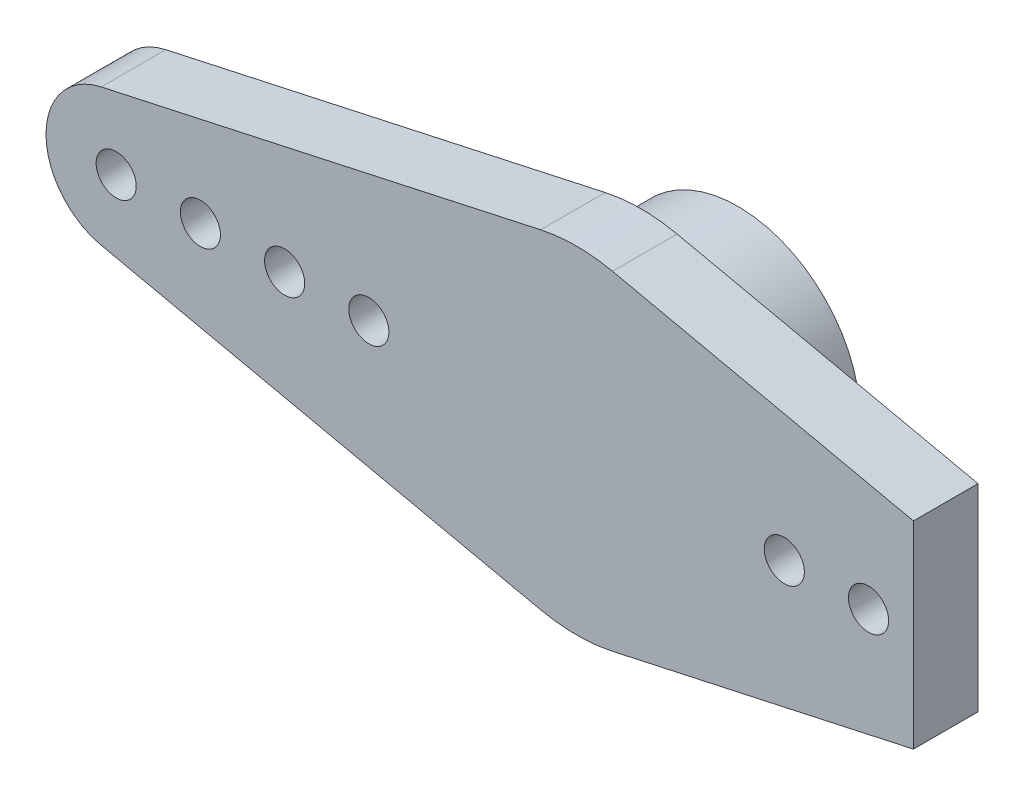
from build123d import *

# Parameters (mm, degrees)
SKETCH_1_R          = 4.35
EXTRUDE_1_DEPTH     = 3.45
SKETCH_2_R          = 0.715
EXTRUDE_2_DEPTH     = 2.3
SKETCH_3_R          = 2.85
CUT_EXTRUDE_1_DEPTH = 3.4
SKETCH_4_W          = 12.90394782
SKETCH_4_H          = 10.561384984
CUT_EXTRUDE_2_DEPTH = 10


with BuildPart() as part:
    # 草图1 → 凸台-拉伸1 (new body)
    with BuildSketch(Plane.XY):
        Circle(SKETCH_1_R)
    extrude(amount=EXTRUDE_1_DEPTH)

    # 草图2 → 凸台-拉伸2 (add)
    with BuildSketch(Plane.XY.offset(3.45)):
        with BuildLine():
            Line((-1.280487805, 5.861770294), (-16.933536585, 2.442404289))
            ThreePointArc((-16.933536585, 2.442404289), (-18.9, 0), (-16.933536585, -2.442404289))
            Line((-16.933536585, -2.442404289), (-1.280487805, -5.861770294))
            ThreePointArc((-1.280487805, -5.861770294), (0, -6), (1.280487805, -5.861770294))
            Line((1.280487805, -5.861770294), (16.933536585, -2.442404289))
            ThreePointArc((16.933536585, -2.442404289), (18.9, 0), (16.933536585, 2.442404289))
            Line((16.933536585, 2.442404289), (1.280487805, 5.861770294))
            ThreePointArc((1.280487805, 5.861770294), (0, 6), (-1.280487805, 5.861770294))
        make_face()
        with Locations((-16.4, 0)):
            Circle(SKETCH_2_R, mode=Mode.SUBTRACT)
        with Locations((-13.4, 0)):
            Circle(SKETCH_2_R, mode=Mode.SUBTRACT)
        with Locations((-10.4, 0)):
            Circle(SKETCH_2_R, mode=Mode.SUBTRACT)
        with Locations((-7.4, 0)):
            Circle(SKETCH_2_R, mode=Mode.SUBTRACT)
        with Locations((7.4, 0)):
            Circle(SKETCH_2_R, mode=Mode.SUBTRACT)
        with Locations((10.4, 0)):
            Circle(SKETCH_2_R, mode=Mode.SUBTRACT)
        with Locations((13.4, 0)):
            Circle(SKETCH_2_R, mode=Mode.SUBTRACT)
        with Locations((16.4, 0)):
            Circle(SKETCH_2_R, mode=Mode.SUBTRACT)
    extrude(amount=EXTRUDE_2_DEPTH)

    # 草图3 → 切除-拉伸1 (cut)
    with BuildSketch(Plane(origin=(0, 0, 0), x_dir=(-1, 0, 0), z_dir=(0, 0, -1))):
        Circle(SKETCH_3_R)
    extrude(amount=-CUT_EXTRUDE_1_DEPTH, mode=Mode.SUBTRACT)

    # 草图4 → 切除-拉伸2 (cut)
    with BuildSketch(Plane.XY.offset(5.75)):
        with Locations((18.45197391, -0.575714595)):
            Rectangle(SKETCH_4_W, SKETCH_4_H)
    extrude(amount=-CUT_EXTRUDE_2_DEPTH, mode=Mode.SUBTRACT)


solid = part.part
